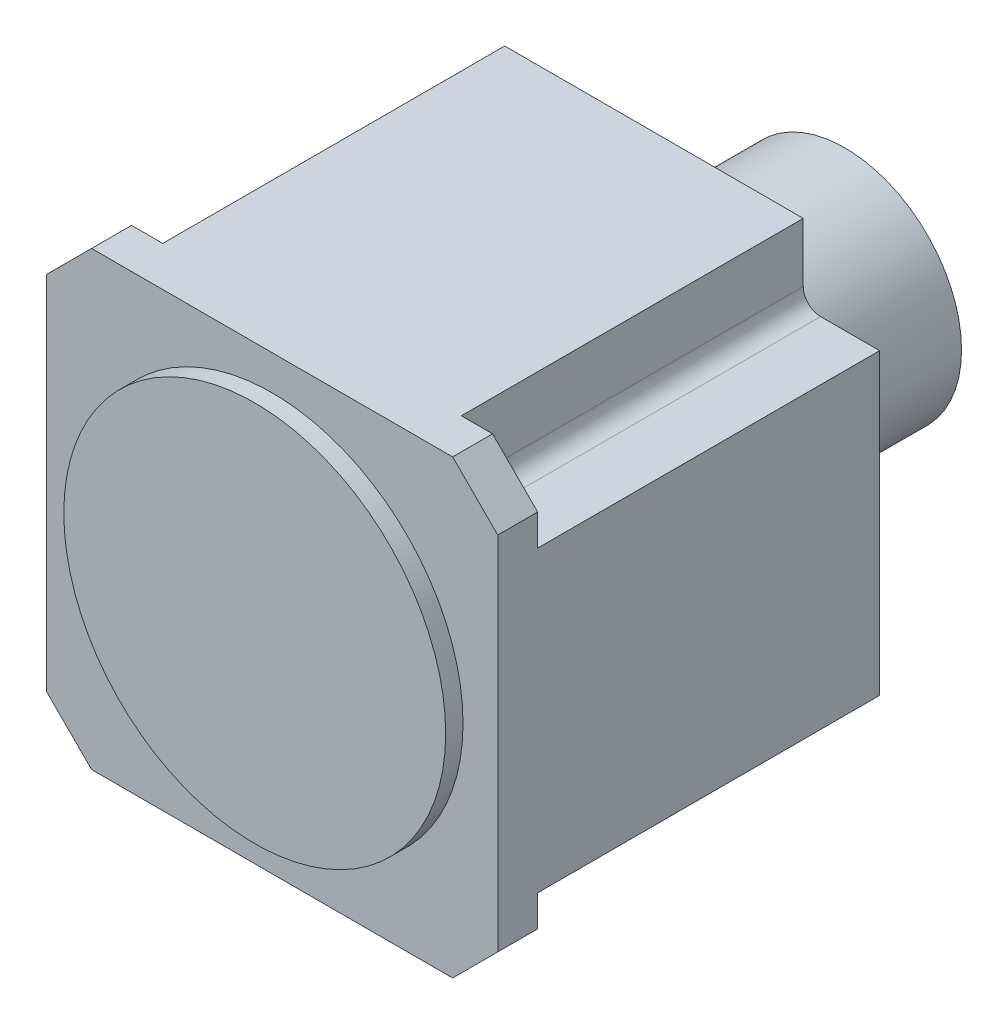
from build123d import *

# Parameters (mm, degrees)
EXTRUDE_1_DEPTH = 11.5
SKETCH_2_R      = 55
EXTRUDE_2_DEPTH = 5
SKETCH_5_W      = 86
SKETCH_5_H      = 22
SKETCH_5_W_2    = 22
SKETCH_5_H_2    = 86
EXTRUDE_4_DEPTH = 98.5
FILLET_1_R      = 5
SKETCH_6_R      = 33.6
EXTRUDE_5_DEPTH = 55


with BuildPart() as part:
    # 草图1 → 凸台-拉伸1 (new body)
    with BuildSketch(Plane.XY):
        Polygon((-65, -52), (-52, -65), (52, -65), (65, -52), (65, 52), (52, 65), (-52, 65), (-65, 52), align=None)
    extrude(amount=EXTRUDE_1_DEPTH)

    # 草图2 → 凸台-拉伸2 (add)
    with BuildSketch(Plane.XY.offset(11.5)):
        Circle(SKETCH_2_R)
    extrude(amount=EXTRUDE_2_DEPTH)

    # 草图5 → 凸台-拉伸4 (add)
    with BuildSketch(Plane(origin=(0, 0, 0), x_dir=(-1, 0, 0), z_dir=(0, 0, -1))):
        with Locations((0, 54)):
            Rectangle(SKETCH_5_W, SKETCH_5_H)
        with Locations((-54, 0)):
            Rectangle(SKETCH_5_W_2, SKETCH_5_H_2)
        Rectangle(SKETCH_5_W, SKETCH_5_H_2)
        with Locations((54, 0)):
            Rectangle(SKETCH_5_W_2, SKETCH_5_H_2)
        with Locations((0, -54)):
            Rectangle(SKETCH_5_W, SKETCH_5_H)
    extrude(amount=EXTRUDE_4_DEPTH)

    # 圆角1
    fillet_1_edges = [part.edges().sort_by_distance(p)[0] for p in [
        (43, 43, -49.25),
        (43, -43, -49.25),
        (-43, -43, -49.25),
        (-43, 43, -49.25),
    ]]
    fillet(fillet_1_edges, radius=FILLET_1_R)

    # 草图6 → 凸台-拉伸5 (add)
    with BuildSketch(Plane(origin=(0, 0, -98.5), x_dir=(-1, 0, 0), z_dir=(0, 0, -1))):
        Circle(SKETCH_6_R)
    extrude(amount=EXTRUDE_5_DEPTH)


solid = part.part
